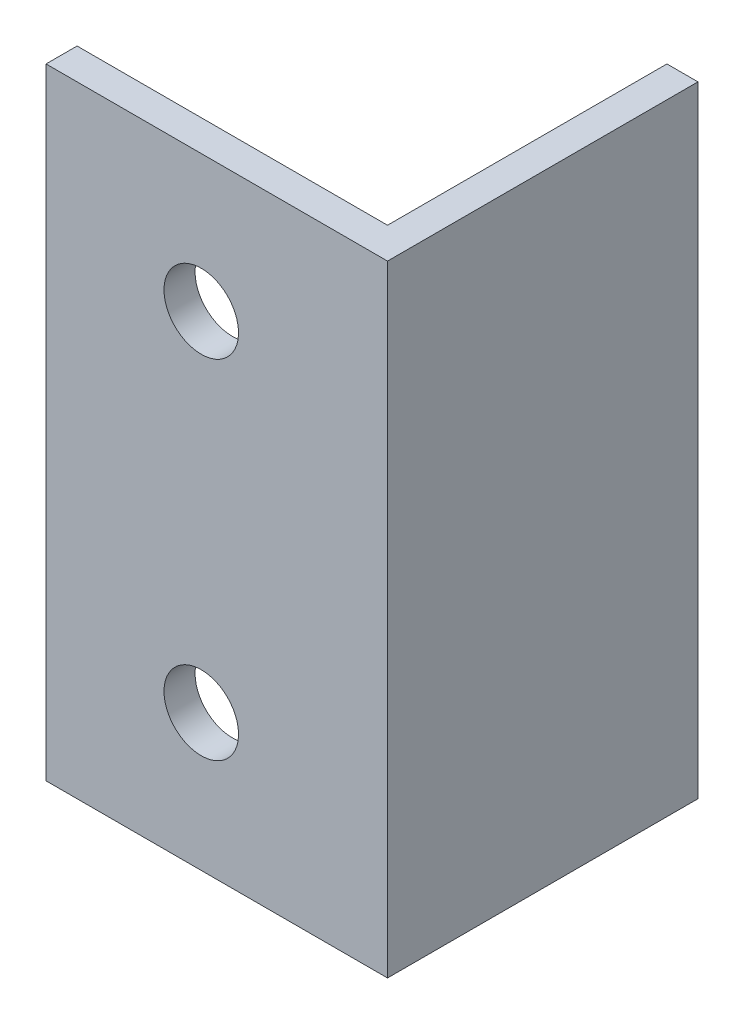
from build123d import *

# Parameters (mm, degrees)
BOSS_EXTRUDE2_DEPTH = 100
CUT_EXTRUDE1_DEPTH  = 100


with BuildPart() as part:
    # Sketch1 → Boss-Extrude2 (new body)
    with BuildSketch(Plane(origin=(0, 0, 0), x_dir=(1, 0, 0), z_dir=(0, 1, 0))):
        Polygon((0, 0), (50, 0), (50, 45), (55, 45), (55, -5), (0, -5), align=None)
    extrude(amount=BOSS_EXTRUDE2_DEPTH)

    # Sketch2 → Cut-Extrude1 (cut)
    with BuildSketch(Plane(origin=(0, 0, 0), x_dir=(-1, 0, 0), z_dir=(0, 0, -1))):
        with BuildLine():
            ThreePointArc((-25, 28), (-31, 22), (-25, 16))
            Line((-25, 16), (-25, 28))
        make_face()
        with BuildLine():
            Line((-25, 28), (-25, 16))
            ThreePointArc((-25, 16), (-20.757359313, 17.757359313), (-19, 22))
            ThreePointArc((-19, 22), (-20.757359313, 26.242640687), (-25, 28))
        make_face()
        with BuildLine():
            ThreePointArc((-25, 84), (-31, 78), (-25, 72))
            Line((-25, 72), (-25, 84))
        make_face()
        with BuildLine():
            Line((-25, 84), (-25, 72))
            ThreePointArc((-25, 72), (-20.757359313, 73.757359313), (-19, 78))
            ThreePointArc((-19, 78), (-20.757359313, 82.242640687), (-25, 84))
        make_face()
    extrude(amount=-CUT_EXTRUDE1_DEPTH, mode=Mode.SUBTRACT)


solid = part.part
